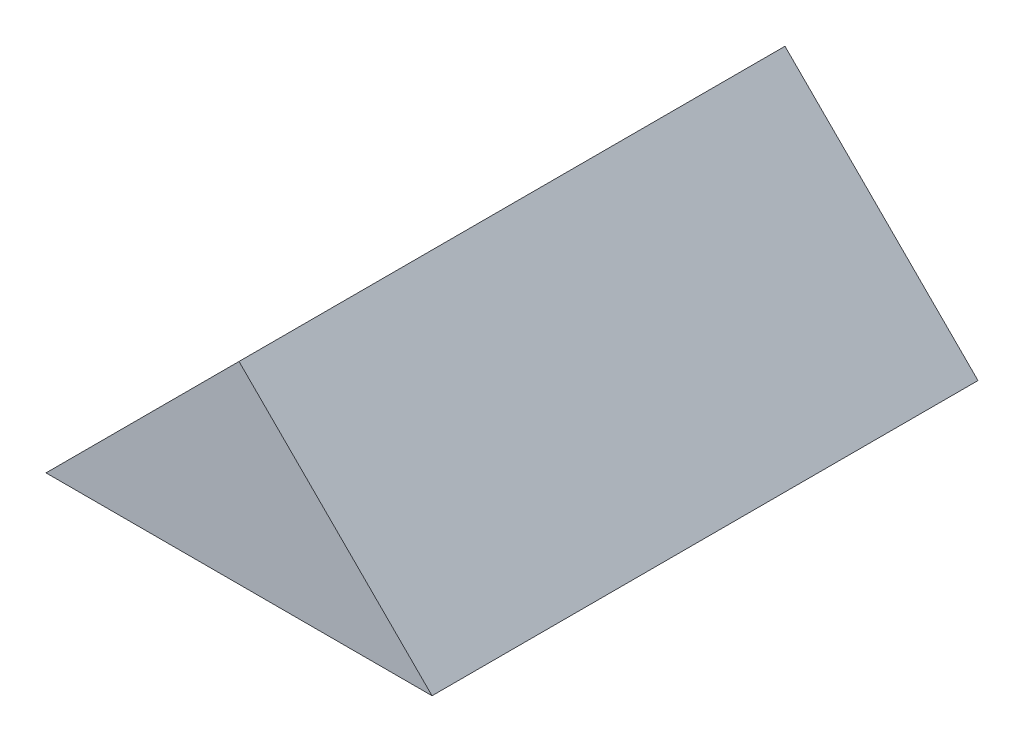
from build123d import *

# Parameters (mm, degrees)
BOSS_EXTRUDE1_DEPTH = 25.4


with BuildPart() as part:
    # Sketch1 → Boss-Extrude1 (new body, symmetric)
    with BuildSketch(Plane.XY):
        Polygon((-17.960512242, 0), (17.960512242, 0), (0, 17.960512242), align=None)
    extrude(amount=BOSS_EXTRUDE1_DEPTH, both=True)


solid = part.part
